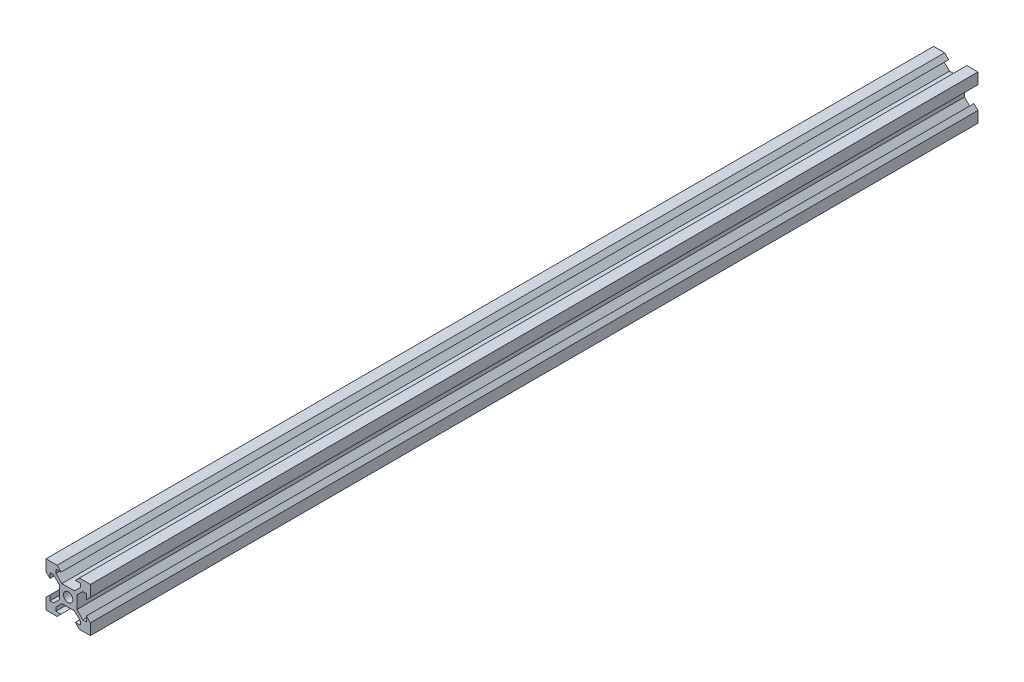
from build123d import *

# Parameters (mm, degrees)
SKETCH1_R           = 2.1
BOSS_EXTRUDE1_DEPTH = 200


with BuildPart() as part:
    # Sketch1 → Boss-Extrude1 (new body, symmetric)
    with BuildSketch(Plane.XY):
        Polygon((-10, 10), (-5, 10), (-3.2, 8.2), (-5.499339828, 8.2), (-5.499339828, 6.56), (-2.84, 3.900660172), (2.84, 3.900660172), (5.499339828, 6.56), (5.499339828, 8.2), (3.2, 8.2), (5, 10), (10, 10), (10, 5), (8.2, 3.2), (8.2, 5.499339828), (6.56, 5.499339828), (3.900660172, 2.84), (3.900660172, -2.84), (6.56, -5.499339828), (8.2, -5.499339828), (8.2, -3.2), (10, -5), (10, -10), (5, -10), (3.2, -8.2), (5.499339828, -8.2), (5.499339828, -6.56), (2.84, -3.900660172), (-2.84, -3.900660172), (-5.499339828, -6.56), (-5.499339828, -8.2), (-3.2, -8.2), (-5, -10), (-10, -10), (-10, -5), (-8.2, -3.2), (-8.2, -5.499339828), (-6.56, -5.499339828), (-3.900660172, -2.84), (-3.900660172, 2.84), (-6.56, 5.499339828), (-8.2, 5.499339828), (-8.2, 3.2), (-10, 5), align=None)
        Circle(SKETCH1_R, mode=Mode.SUBTRACT)
    extrude(amount=BOSS_EXTRUDE1_DEPTH, both=True)


solid = part.part
